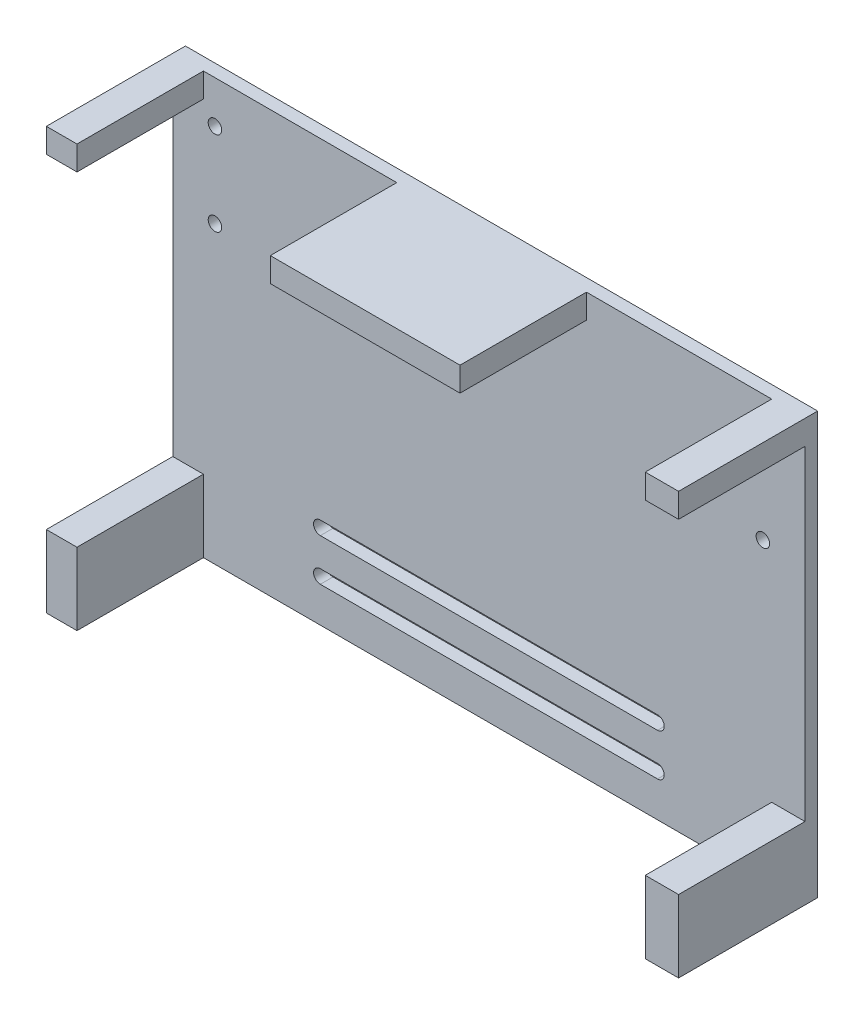
from build123d import *

# Parameters (mm, degrees)
SKETCH_1_W          = 150
SKETCH_1_H          = 100
SKETCH_1_R          = 1.6
EXTRUDE_1_DEPTH     = 3
SKETCH_2_W          = 45.012904103
SKETCH_2_H          = 5.754361308
SKETCH_2_W_2        = 7.270480745
SKETCH_2_W_3        = 7.901217153
SKETCH_2_H_2        = 17.152026815
EXTRUDE_2_DEPTH     = 30
CUT_EXTRUDE_1_DEPTH = 5


with BuildPart() as part:
    # 草图1 → 凸台-拉伸1 (new body)
    with BuildSketch(Plane.XY):
        with Locations((18.212237094, -8.671684116)):
            Rectangle(SKETCH_1_W, SKETCH_1_H)
        with Locations((-46.787762906, 31.328315884)):
            Circle(SKETCH_1_R, mode=Mode.SUBTRACT)
        with Locations((-46.787762906, 11.328315884)):
            Circle(SKETCH_1_R, mode=Mode.SUBTRACT)
        with Locations((83.212237094, 11.328315884)):
            Circle(SKETCH_1_R, mode=Mode.SUBTRACT)
        with Locations((83.212237094, 31.328315884)):
            Circle(SKETCH_1_R, mode=Mode.SUBTRACT)
    extrude(amount=EXTRUDE_1_DEPTH)

    # 草图2 → 凸台-拉伸2 (add)
    with BuildSketch(Plane.XY.offset(3)):
        with Locations((18.854591116, 38.45113523)):
            Rectangle(SKETCH_2_W, SKETCH_2_H)
        with Locations((-53.152522534, 38.45113523)):
            Rectangle(SKETCH_2_W_2, SKETCH_2_H)
        with Locations((89.261628518, 38.45113523)):
            Rectangle(SKETCH_2_W_3, SKETCH_2_H)
        with Locations((89.261628518, -50.095670709)):
            Rectangle(SKETCH_2_W_3, SKETCH_2_H_2)
        with Locations((-53.152522534, -50.095670709)):
            Rectangle(SKETCH_2_W_2, SKETCH_2_H_2)
    extrude(amount=EXTRUDE_2_DEPTH)

    # 草图3 → 切除-拉伸1 (cut)
    with BuildSketch(Plane(origin=(0, 0, 0), x_dir=(-1, 0, 0), z_dir=(0, 0, -1))):
        with BuildLine():
            Line((-58.212237094, -37.071684116), (21.787762906, -37.071684116))
            ThreePointArc((21.787762906, -37.071684116), (23.387762906, -38.671684116), (21.787762906, -40.271684116))
            Line((21.787762906, -40.271684116), (-58.212237094, -40.271684116))
            ThreePointArc((-58.212237094, -40.271684116), (-59.812237094, -38.671684116), (-58.212237094, -37.071684116))
        make_face()
        with BuildLine():
            Line((-58.212237094, -47.071684116), (21.787762906, -47.071684116))
            ThreePointArc((21.787762906, -47.071684116), (23.387762906, -48.671684116), (21.787762906, -50.271684116))
            Line((21.787762906, -50.271684116), (-58.212237094, -50.271684116))
            ThreePointArc((-58.212237094, -50.271684116), (-59.812237094, -48.671684116), (-58.212237094, -47.071684116))
        make_face()
    extrude(amount=-CUT_EXTRUDE_1_DEPTH, mode=Mode.SUBTRACT)


solid = part.part
